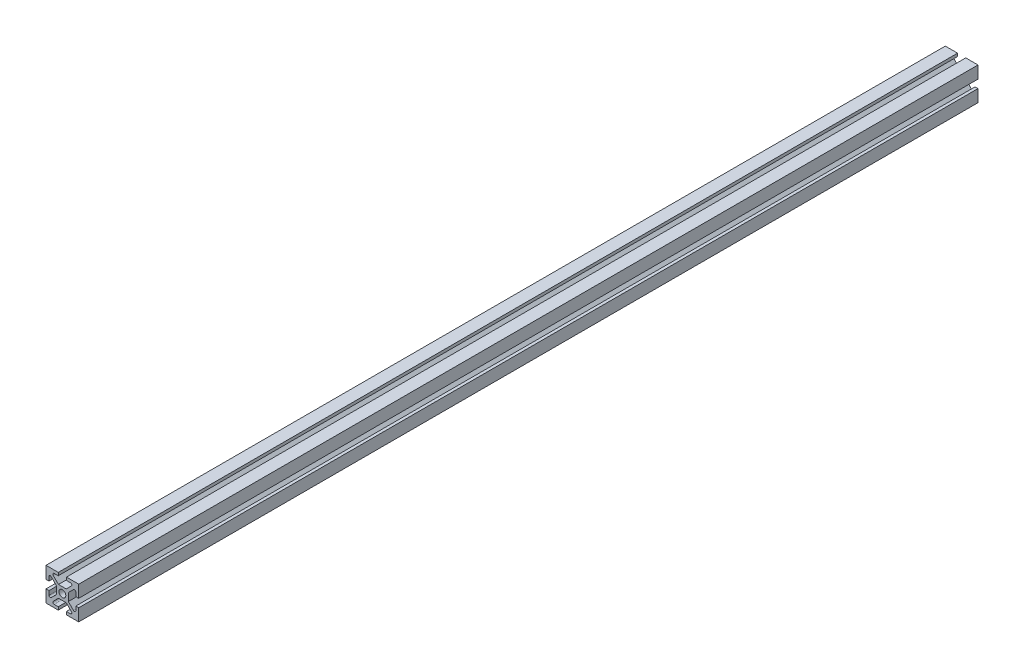
from build123d import *

# Parameters (mm, degrees)
CROQUIS15_R             = 2.1
SALIENTE_EXTRUIR2_DEPTH = 550


with BuildPart() as part:
    # Croquis15 → Saliente-Extruir2 (new body)
    with BuildSketch(Plane.XY):
        with BuildLine():
            Line((-10, -10), (-10, -2.5))
            Line((-10, -2.5), (-8.2, -2.5))
            Line((-8.2, -2.5), (-8.2, -4.995836944))
            ThreePointArc((-8.2, -4.995836944), (-7.706146746, -5.73494057), (-6.834314575, -5.561522369))
            Line((-6.834314575, -5.561522369), (-3.65, -2.377207794))
            Line((-3.65, -2.377207794), (-3.65, 2.377207794))
            Line((-3.65, 2.377207794), (-6.834314575, 5.561522369))
            ThreePointArc((-6.834314575, 5.561522369), (-7.706146746, 5.73494057), (-8.2, 4.995836944))
            Line((-8.2, 4.995836944), (-8.2, 2.5))
            Line((-8.2, 2.5), (-10, 2.5))
            Line((-10, 2.5), (-10, 10))
            Line((-10, 10), (-2.5, 10))
            Line((-2.5, 10), (-2.5, 8.2))
            Line((-2.5, 8.2), (-4.995836944, 8.2))
            ThreePointArc((-4.995836944, 8.2), (-5.73494057, 7.706146746), (-5.561522369, 6.834314575))
            Line((-5.561522369, 6.834314575), (-2.377207794, 3.65))
            Line((-2.377207794, 3.65), (2.377207794, 3.65))
            Line((2.377207794, 3.65), (5.561522369, 6.834314575))
            ThreePointArc((5.561522369, 6.834314575), (5.73494057, 7.706146746), (4.995836944, 8.2))
            Line((4.995836944, 8.2), (2.5, 8.2))
            Line((2.5, 8.2), (2.5, 10))
            Line((2.5, 10), (10, 10))
            Line((10, 10), (10, 2.5))
            Line((10, 2.5), (8.2, 2.5))
            Line((8.2, 2.5), (8.2, 4.995836944))
            ThreePointArc((8.2, 4.995836944), (7.706146746, 5.73494057), (6.834314575, 5.561522369))
            Line((6.834314575, 5.561522369), (3.65, 2.377207794))
            Line((3.65, 2.377207794), (3.65, -2.377207794))
            Line((3.65, -2.377207794), (6.834314575, -5.561522369))
            ThreePointArc((6.834314575, -5.561522369), (7.706146746, -5.73494057), (8.2, -4.995836944))
            Line((8.2, -4.995836944), (8.2, -2.5))
            Line((8.2, -2.5), (10, -2.5))
            Line((10, -2.5), (10, -10))
            Line((10, -10), (2.5, -10))
            Line((2.5, -10), (2.5, -8.2))
            Line((2.5, -8.2), (4.995836944, -8.2))
            ThreePointArc((4.995836944, -8.2), (5.73494057, -7.706146746), (5.561522369, -6.834314575))
            Line((5.561522369, -6.834314575), (2.377207794, -3.65))
            Line((2.377207794, -3.65), (-2.377207794, -3.65))
            Line((-2.377207794, -3.65), (-5.561522369, -6.834314575))
            ThreePointArc((-5.561522369, -6.834314575), (-5.73494057, -7.706146746), (-4.995836944, -8.2))
            Line((-4.995836944, -8.2), (-2.5, -8.2))
            Line((-2.5, -8.2), (-2.5, -10))
            Line((-2.5, -10), (-10, -10))
        make_face()
        Circle(CROQUIS15_R, mode=Mode.SUBTRACT)
    extrude(amount=-SALIENTE_EXTRUIR2_DEPTH)


solid = part.part
